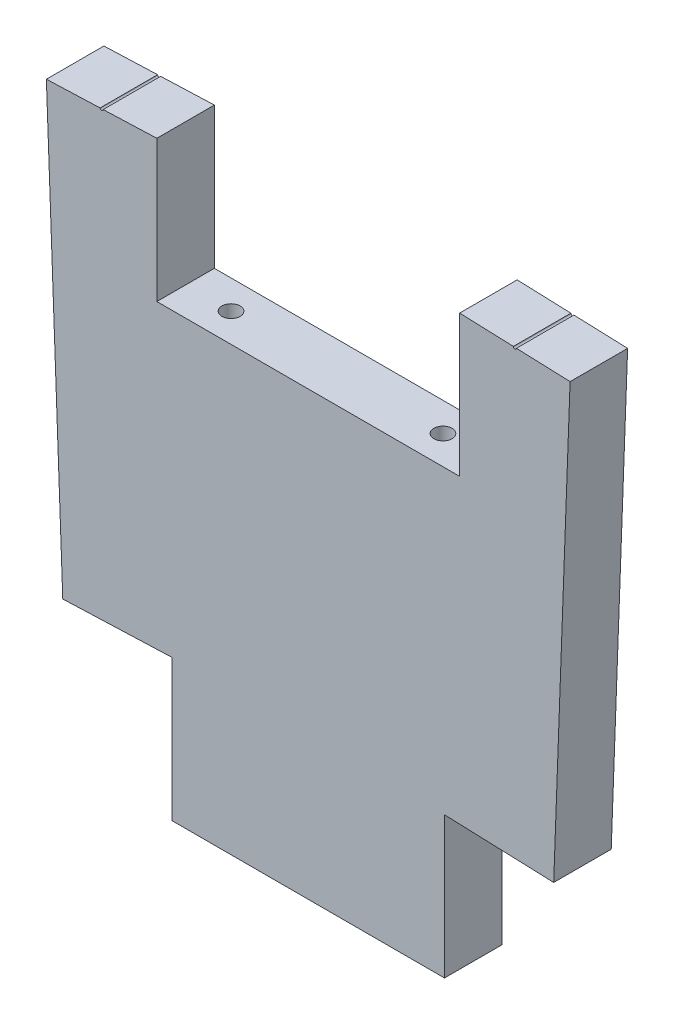
from build123d import *

# Parameters (mm, degrees)
BOSS_EXTRUDE1_DEPTH = 19
CUT_EXTRUDE1_DEPTH  = 19
SKETCH6_R           = 3
CUT_EXTRUDE2_DEPTH  = 10
SKETCH7_R           = 0.5
CUT_EXTRUDE3_DEPTH  = 20


with BuildPart() as part:
    # Sketch2 → Boss-Extrude1 (new body)
    with BuildSketch(Plane.XY):
        Polygon((-50, -12.7), (50, -12.7), (50, 34.001988406), (86.488954477, 32.648136171), (79.389661188, -158.69164437), (-79.389661188, -158.69164437), (-86.488954477, 32.648136171), (-50, 34.001988406), align=None)
    extrude(amount=-BOSS_EXTRUDE1_DEPTH)

    # Sketch4 → Cut-Extrude1 (cut)
    with BuildSketch(Plane(origin=(0, 0, -19), x_dir=(-1, 0, 0), z_dir=(0, 0, -1))):
        Polygon((176.999986596, -116.887260719), (45, -111.989655964), (45, -158.69164437), (-45, -158.69164437), (-45, -111.989655964), (-160.814787096, -116.286740127), (-160.814787096, -226.328943165), (176.999986596, -226.328943165), align=None)
    extrude(amount=-CUT_EXTRUDE1_DEPTH, mode=Mode.SUBTRACT)

    # Sketch6 → Cut-Extrude2 (cut)
    with BuildSketch(Plane(origin=(0, -12.7, 0), x_dir=(1, 0, 0), z_dir=(0, 1, 0))):
        with Locations((35, 9.5)):
            Circle(SKETCH6_R)
        with Locations((-35, 9.5)):
            Circle(SKETCH6_R)
    extrude(amount=-CUT_EXTRUDE2_DEPTH, mode=Mode.SUBTRACT)

    # Sketch7 → Cut-Extrude3 (cut)
    with BuildSketch(Plane(origin=(0, 0, -19), x_dir=(-1, 0, 0), z_dir=(0, 0, -1))):
        with Locations((68.244477239, 33.325062289)):
            Circle(SKETCH7_R)
        with Locations((-68.244477239, 33.325062289)):
            Circle(SKETCH7_R)
    extrude(amount=-CUT_EXTRUDE3_DEPTH, mode=Mode.SUBTRACT)


solid = part.part
